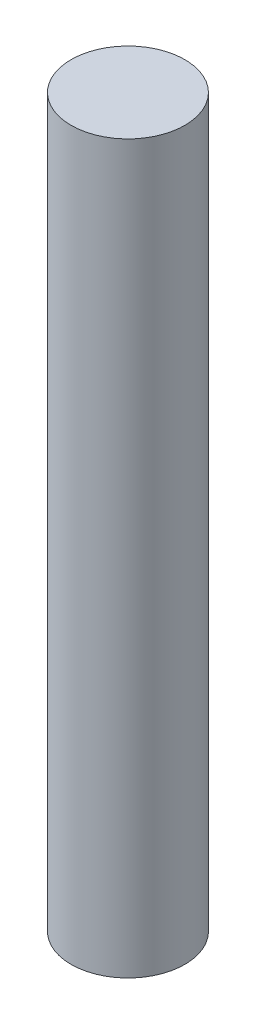
from build123d import *

# Parameters (mm, degrees)
SKETCH3_R           = 0.47
BOSS_EXTRUDE1_DEPTH = 6


with BuildPart() as part:
    # Sketch3 → Boss-Extrude1 (new body)
    with BuildSketch(Plane(origin=(0, 0, 0), x_dir=(1, 0, 0), z_dir=(0, 1, 0))):
        Circle(SKETCH3_R)
    extrude(amount=BOSS_EXTRUDE1_DEPTH)


solid = part.part
